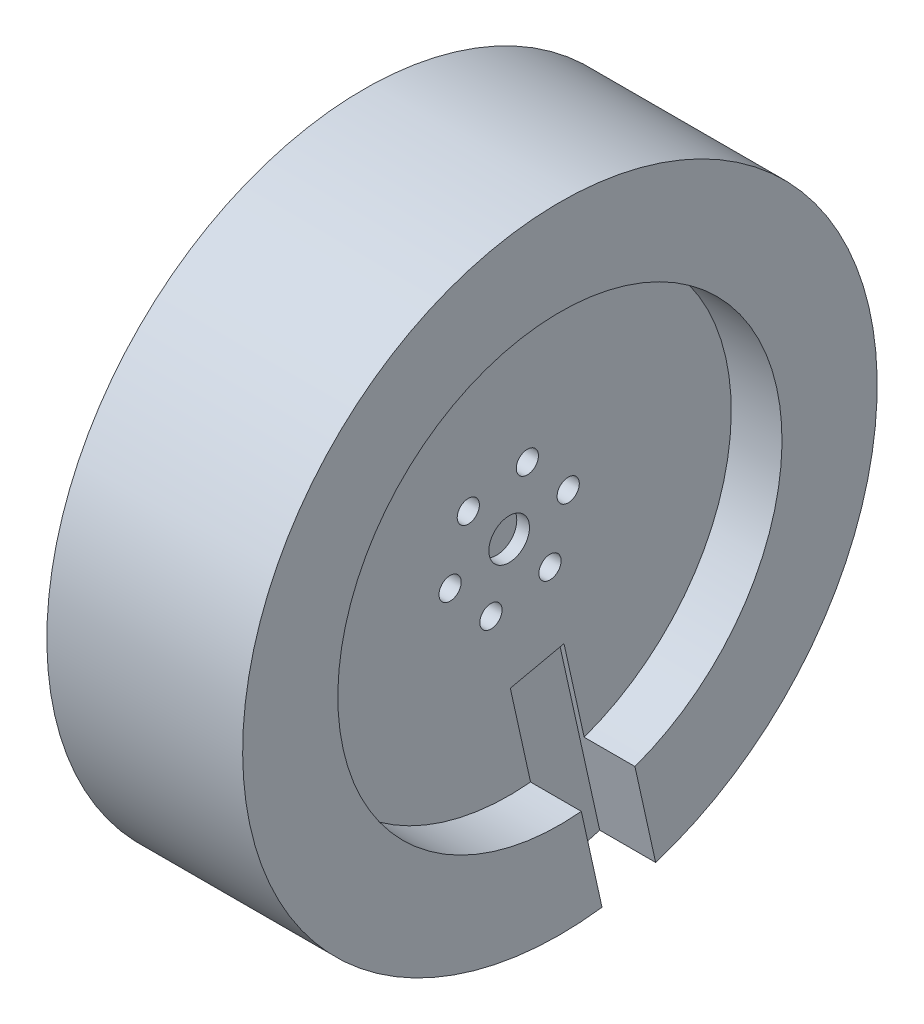
from build123d import *

# Parameters (mm, degrees)
SKETCH1_R           = 50
BOSS_EXTRUDE1_DEPTH = 30.86
SKETCH2_R           = 35
CUT_EXTRUDE1_DEPTH  = 8
CUT_EXTRUDE4_START  = -20
SKETCH10_W          = 10.01875972
SKETCH10_H          = 8.661840267
CUT_EXTRUDE4_DEPTH  = 60
SKETCH12_R          = 3.2
CUT_EXTRUDE5_DEPTH  = 2
SKETCH5_R           = 1.75
CUT_EXTRUDE3_DEPTH  = 30
SKETCH8_R           = 4
CUT_EXTRUDE6_DEPTH  = 10


with BuildPart() as part:
    # Sketch1 → Boss-Extrude1 (new body)
    with BuildSketch(Plane(origin=(0, 0, 0), x_dir=(0, 0, -1), z_dir=(1, 0, 0))):
        Circle(SKETCH1_R)
    extrude(amount=BOSS_EXTRUDE1_DEPTH)

    # Sketch2 → Cut-Extrude1 (cut)
    with BuildSketch(Plane(origin=(30.86, 0, 0), x_dir=(0, 0, -1), z_dir=(1, 0, 0))):
        Circle(SKETCH2_R)
    extrude(amount=-CUT_EXTRUDE1_DEPTH, mode=Mode.SUBTRACT)

    # Sketch10 → Cut-Extrude4 (cut)
    with BuildSketch(Plane(origin=(0, 0, 0), x_dir=(1, 0, 0), z_dir=(0, 0.9763565991877232, 0.2161661195066977)).offset(CUT_EXTRUDE4_START)):
        with Locations((27.048757514, 0.091052199)):
            Rectangle(SKETCH10_W, SKETCH10_H)
    extrude(amount=-CUT_EXTRUDE4_DEPTH, mode=Mode.SUBTRACT)

    # Sketch12 → Cut-Extrude5 (cut)
    with BuildSketch(Plane(origin=(22.86, 0, 0), x_dir=(0, 0, -1), z_dir=(1, 0, 0))):
        Circle(SKETCH12_R)
    extrude(amount=-CUT_EXTRUDE5_DEPTH, mode=Mode.SUBTRACT)

    # Sketch5 → Cut-Extrude3 (cut)
    with BuildSketch(Plane.ZY):
        with Locations((2.868272201, -9.088119419)):
            Circle(SKETCH5_R)
        with Locations((-6.436406189, -7.028056301)):
            Circle(SKETCH5_R)
        with Locations((-9.30467839, 2.060063119)):
            Circle(SKETCH5_R)
        with Locations((-2.868272201, 9.088119419)):
            Circle(SKETCH5_R)
        with Locations((6.436406189, 7.028056301)):
            Circle(SKETCH5_R)
        with Locations((9.30467839, -2.060063119)):
            Circle(SKETCH5_R)
    extrude(amount=-CUT_EXTRUDE3_DEPTH, mode=Mode.SUBTRACT)

    # Sketch8 → Cut-Extrude6 (cut)
    with BuildSketch(Plane.ZY):
        with Locations((-2.868272201, 9.088119419)):
            Circle(SKETCH8_R)
        with Locations((6.436406189, 7.028056301)):
            Circle(SKETCH8_R)
        with Locations((9.30467839, -2.060063119)):
            Circle(SKETCH8_R)
        with Locations((2.868272201, -9.088119419)):
            Circle(SKETCH8_R)
        with Locations((-6.436406189, -7.028056301)):
            Circle(SKETCH8_R)
        with Locations((-9.30467839, 2.060063119)):
            Circle(SKETCH8_R)
    extrude(amount=-CUT_EXTRUDE6_DEPTH, mode=Mode.SUBTRACT)


solid = part.part
